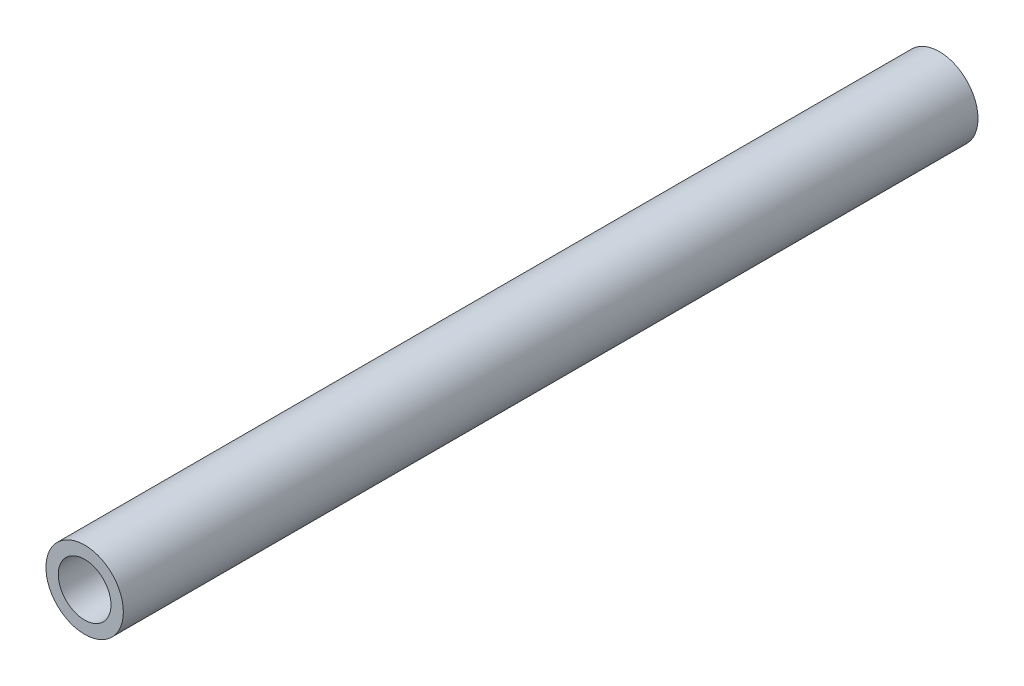
from build123d import *

# Parameters (mm, degrees)
SKETCH2_R           = 6.25
SKETCH2_R_2         = 4.25
BOSS_EXTRUDE1_DEPTH = 138


with BuildPart() as part:
    # Sketch2 → Boss-Extrude1 (new body)
    with BuildSketch(Plane.XY):
        with Locations((-36.480993275, 23.345303087)):
            Circle(SKETCH2_R)
        with Locations((-36.480993275, 23.345303087)):
            Circle(SKETCH2_R_2, mode=Mode.SUBTRACT)
    extrude(amount=BOSS_EXTRUDE1_DEPTH)


solid = part.part
